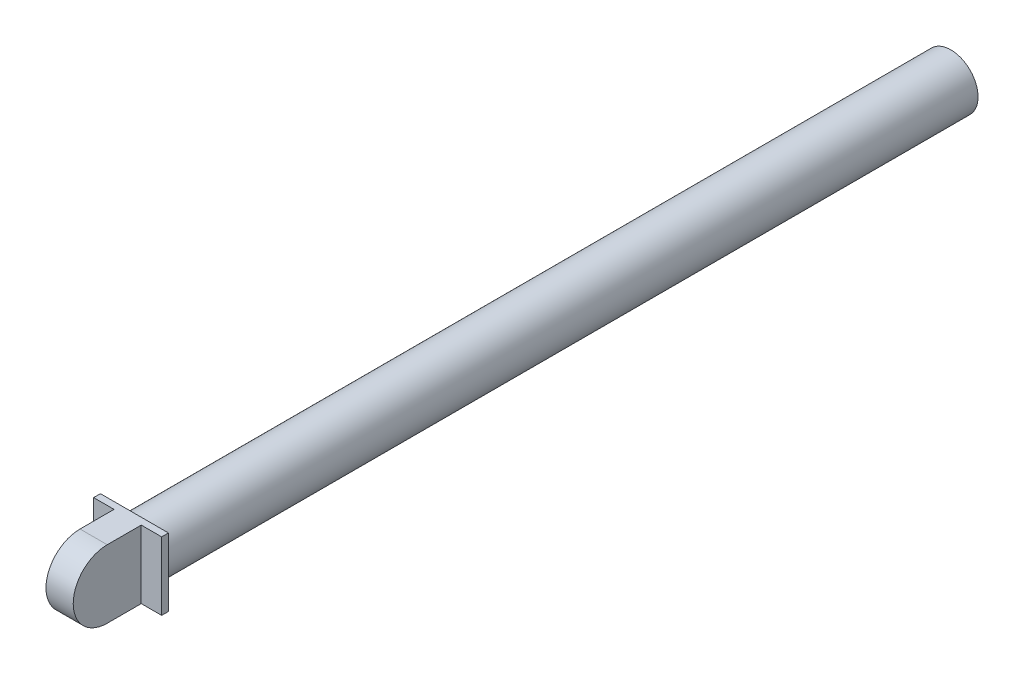
from build123d import *

# Parameters (mm, degrees)
SKETCH_1_W          = 10
SKETCH_1_H          = 10
EXTRUDE_1_DEPTH     = 11
SKETCH_2_W          = 3
SKETCH_2_H          = 10
CUT_EXTRUDE_1_DEPTH = 11
SKETCH_3_R          = 4
EXTRUDE_2_DEPTH     = 120
CUT_EXTRUDE_2_DEPTH = 80


with BuildPart() as part:
    # 草图1 → 凸台-拉伸1 (new body)
    with BuildSketch(Plane.XY):
        Rectangle(SKETCH_1_W, SKETCH_1_H)
    extrude(amount=EXTRUDE_1_DEPTH)

    # 草图2 → 切除-拉伸1 (cut)
    with BuildSketch(Plane(origin=(0, 5, 0), x_dir=(1, 0, 0), z_dir=(0, 1, 0))):
        with Locations((-3.5, -6)):
            Rectangle(SKETCH_2_W, SKETCH_2_H)
        with Locations((3.5, -6)):
            Rectangle(SKETCH_2_W, SKETCH_2_H)
    extrude(amount=-CUT_EXTRUDE_1_DEPTH, mode=Mode.SUBTRACT)

    # 草图3 → 凸台-拉伸2 (add)
    with BuildSketch(Plane(origin=(0, 0, 0), x_dir=(-1, 0, 0), z_dir=(0, 0, -1))):
        Circle(SKETCH_3_R)
    extrude(amount=EXTRUDE_2_DEPTH)

    # 草图4 → 切除-拉伸2 (cut)
    with BuildSketch(Plane(origin=(2, 0, 0), x_dir=(0, 0, -1), z_dir=(1, 0, 0))):
        with BuildLine():
            Line((-6, 5), (-12.295699944, 5))
            Line((-12.295699944, 5), (-12.295699944, -5))
            Line((-12.295699944, -5), (-6, -5))
            ThreePointArc((-6, -5), (-11, 0), (-6, 5))
        make_face()
    extrude(amount=-CUT_EXTRUDE_2_DEPTH, mode=Mode.SUBTRACT)


solid = part.part
